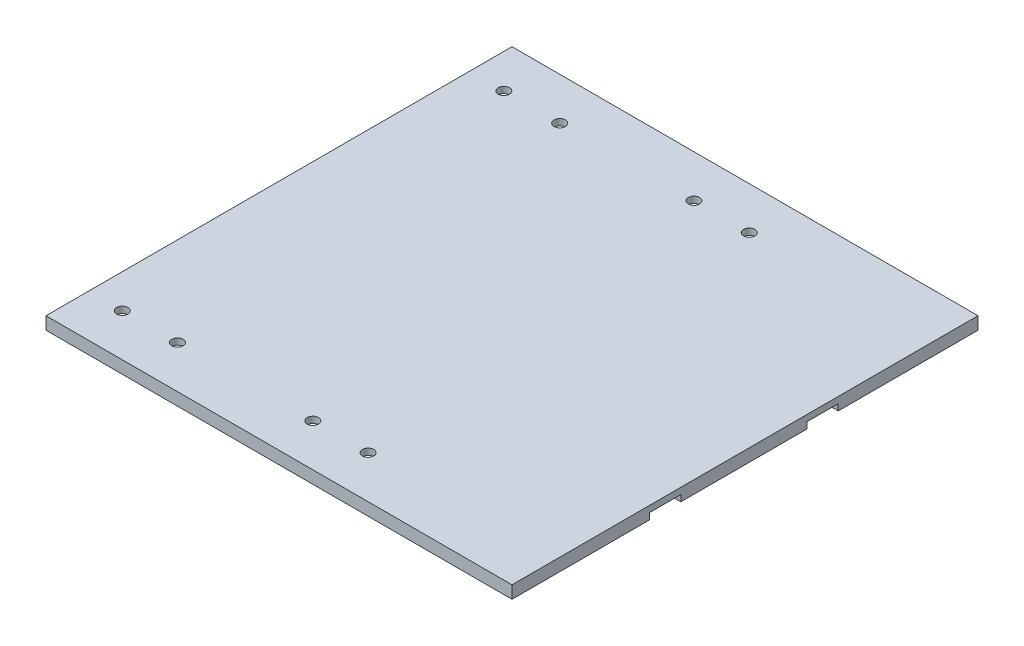
from build123d import *

# Parameters (mm, degrees)
ESQUISSE1_W              = 148
ESQUISSE1_H              = 148
BOSS_EXTRU_1_DEPTH       = 4
ESQUISSE4_R              = 1.8
ENL_V_MAT_EXTRU_2_DEPTH  = 4
ESQUISSE5_W              = 35.5
ESQUISSE5_H              = 23.5
ENL_V_MAT_EXTRU_3_DEPTH  = 2
ESQUISSE8_R              = 1.8
ENL_V_MAT_EXTRU_6_DEPTH  = 4
ESQUISSE9_W              = 35.5
ESQUISSE9_H              = 23.5
ENL_V_MAT_EXTRU_7_DEPTH  = 2
ESQUISSE10_R             = 1.8
ENL_V_MAT_EXTRU_8_DEPTH  = 4
ESQUISSE11_W             = 35.5
ESQUISSE11_H             = 23.5
ESQUISSE11_H_2           = 23.512269398
ENL_V_MAT_EXTRU_9_DEPTH  = 2
ESQUISSE12_W             = 23.640980831
ESQUISSE12_H             = 10
ESQUISSE12_W_2           = 17.131931469
ENL_V_MAT_EXTRU_12_DEPTH = 2


with BuildPart() as part:
    # Esquisse1 → Boss.-Extru.1 (new body)
    with BuildSketch(Plane(origin=(0, 0, 0), x_dir=(1, 0, 0), z_dir=(0, 1, 0))):
        Rectangle(ESQUISSE1_W, ESQUISSE1_H)
    extrude(amount=BOSS_EXTRU_1_DEPTH)

    # Esquisse4 → Enlèv. mat.-Extru.2 (cut)
    with BuildSketch(Plane(origin=(0, 0, 0), x_dir=(1, 0, 0), z_dir=(0, 1, 0))):
        with Locations((-63.25, -60.525)):
            Circle(ESQUISSE4_R)
        with Locations((-45.75, -60.525)):
            Circle(ESQUISSE4_R)
    extrude(amount=ENL_V_MAT_EXTRU_2_DEPTH, mode=Mode.SUBTRACT)

    # Esquisse5 → Enlèv. mat.-Extru.3 (cut)
    with BuildSketch(Plane(origin=(0, 0, 0), x_dir=(1, 0, 0), z_dir=(0, 1, 0))):
        with Locations((-54.25, -60.25)):
            Rectangle(ESQUISSE5_W, ESQUISSE5_H)
    extrude(amount=ENL_V_MAT_EXTRU_3_DEPTH, mode=Mode.SUBTRACT)

    # Esquisse8 → Enlèv. mat.-Extru.6 (cut)
    with BuildSketch(Plane(origin=(0, 0, 0), x_dir=(1, 0, 0), z_dir=(0, 1, 0))):
        with Locations((-2.725, -60.525)):
            Circle(ESQUISSE8_R)
        with Locations((14.825, -60.525)):
            Circle(ESQUISSE8_R)
    extrude(amount=ENL_V_MAT_EXTRU_6_DEPTH, mode=Mode.SUBTRACT)

    # Esquisse9 → Enlèv. mat.-Extru.7 (cut)
    with BuildSketch(Plane(origin=(0, 0, 0), x_dir=(1, 0, 0), z_dir=(0, 1, 0))):
        with Locations((6.25, -60.25)):
            Rectangle(ESQUISSE9_W, ESQUISSE9_H)
    extrude(amount=ENL_V_MAT_EXTRU_7_DEPTH, mode=Mode.SUBTRACT)

    # Esquisse10 → Enlèv. mat.-Extru.8 (cut)
    with BuildSketch(Plane(origin=(0, 0, 0), x_dir=(1, 0, 0), z_dir=(0, 1, 0))):
        with Locations((-2.725, 60.525)):
            Circle(ESQUISSE10_R)
        with Locations((14.825, 60.525)):
            Circle(ESQUISSE10_R)
        with Locations((-63.125, 60.525)):
            Circle(ESQUISSE10_R)
        with Locations((-45.375, 60.525)):
            Circle(ESQUISSE10_R)
    extrude(amount=ENL_V_MAT_EXTRU_8_DEPTH, mode=Mode.SUBTRACT)

    # Esquisse11 → Enlèv. mat.-Extru.9 (cut)
    with BuildSketch(Plane(origin=(0, 0, 0), x_dir=(1, 0, 0), z_dir=(0, 1, 0))):
        with Locations((-54.25, 60.25)):
            Rectangle(ESQUISSE11_W, ESQUISSE11_H)
        with Locations((6.25, 60.243865301)):
            Rectangle(ESQUISSE11_W, ESQUISSE11_H_2)
    extrude(amount=ENL_V_MAT_EXTRU_9_DEPTH, mode=Mode.SUBTRACT)

    # Esquisse12 → Enlèv. mat.-Extru.12 (cut)
    with BuildSketch(Plane(origin=(0, 0, 0), x_dir=(1, 0, 0), z_dir=(0, 1, 0))):
        with Locations((68.740682109, -25.384218458)):
            Rectangle(ESQUISSE12_W, ESQUISSE12_H)
        with Locations((65.486157429, 24.615781542)):
            Rectangle(ESQUISSE12_W_2, ESQUISSE12_H)
    extrude(amount=ENL_V_MAT_EXTRU_12_DEPTH, mode=Mode.SUBTRACT)


solid = part.part
